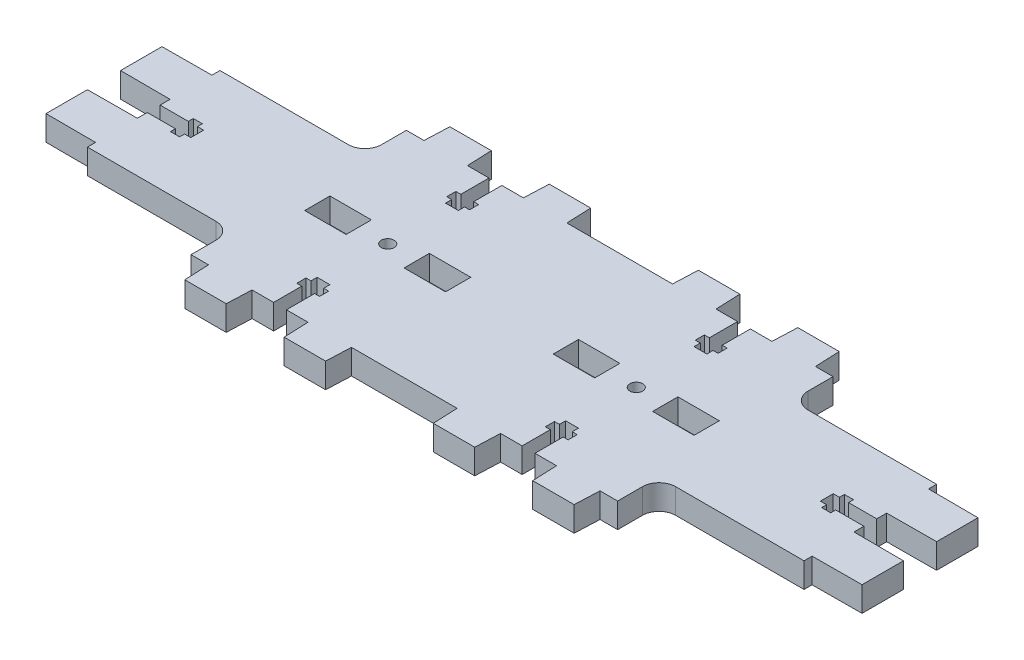
from build123d import *

# Parameters (mm, degrees)
SKETCH_1_R      = 1.55
SKETCH_1_W      = 10
SKETCH_1_H      = 6.1
EXTRUDE_1_DEPTH = 6


with BuildPart() as part:
    # Эскиз1 → Бобышка-Вытянуть1 (new body)
    with BuildSketch(Plane(origin=(0, 0, 0), x_dir=(1, 0, 0), z_dir=(0, 1, 0))):
        with BuildLine():
            Line((40.261608154, 29.273839185), (40.011608154, 23.273839185))
            Line((40.011608154, 23.273839185), (14.511608154, 23.273839185))
            Line((14.511608154, 23.273839185), (14.261608154, 29.273839185))
            Line((14.261608154, 29.273839185), (4.261608154, 29.273839185))
            Line((4.261608154, 29.273839185), (4.011608154, 23.273839185))
            Line((4.011608154, 23.273839185), (-1.188391846, 23.273839185))
            Line((-1.188391846, 23.273839185), (-1.188391846, 16.473839185))
            Line((-1.188391846, 16.473839185), (0.011608154, 16.473839185))
            Line((0.011608154, 16.473839185), (0.011608154, 14.273839185))
            Line((0.011608154, 14.273839185), (-1.188391846, 14.273839185))
            Line((-1.188391846, 14.273839185), (-1.188391846, 12.773839185))
            Line((-1.188391846, 12.773839185), (-4.288391846, 12.773839185))
            Line((-4.288391846, 12.773839185), (-4.288391846, 14.273839185))
            Line((-4.288391846, 14.273839185), (-5.488391846, 14.273839185))
            Line((-5.488391846, 14.273839185), (-5.488391846, 16.473839185))
            Line((-5.488391846, 16.473839185), (-4.288391846, 16.473839185))
            Line((-4.288391846, 16.473839185), (-4.288391846, 23.273839185))
            Line((-4.288391846, 23.273839185), (-9.488391846, 23.273839185))
            Line((-9.488391846, 23.273839185), (-9.738391846, 29.273839185))
            Line((-9.738391846, 29.273839185), (-19.738391846, 29.273839185))
            Line((-19.738391846, 29.273839185), (-19.988391846, 23.273839185))
            Line((-19.988391846, 23.273839185), (-24.238391846, 23.273839185))
            Line((-24.238391846, 23.273839185), (-24.238391846, 17.273839185))
            ThreePointArc((-24.238391846, 17.273839185), (-25.409964721, 14.44541206), (-28.238391846, 13.273839185))
            Line((-28.238391846, 13.273839185), (-59.238391846, 13.273839185))
            Line((-59.238391846, 13.273839185), (-59.238391846, 11.323839185))
            Line((-59.238391846, 11.323839185), (-71.238391846, 11.273839185))
            Line((-71.238391846, 11.273839185), (-71.238391846, 1.273839185))
            Line((-71.238391846, 1.273839185), (-59.238391846, 1.223839185))
            Line((-59.238391846, 1.223839185), (-59.238391846, -1.176160815))
            Line((-59.238391846, -1.176160815), (-52.438391846, -1.176160815))
            Line((-52.438391846, -1.176160815), (-52.438391846, 0.023839185))
            Line((-52.438391846, 0.023839185), (-50.238391846, 0.023839185))
            Line((-50.238391846, 0.023839185), (-50.238391846, -1.176160815))
            Line((-50.238391846, -1.176160815), (-48.738391846, -1.176160815))
            Line((-48.738391846, -1.176160815), (-48.738391846, -4.276160815))
            Line((-48.738391846, -4.276160815), (-50.238391846, -4.276160815))
            Line((-50.238391846, -4.276160815), (-50.238391846, -5.476160815))
            Line((-50.238391846, -5.476160815), (-52.438391846, -5.476160815))
            Line((-52.438391846, -5.476160815), (-52.438391846, -4.276160815))
            Line((-52.438391846, -4.276160815), (-59.238391846, -4.276160815))
            Line((-59.238391846, -4.276160815), (-59.238391846, -6.676160815))
            Line((-59.238391846, -6.676160815), (-71.238391846, -6.726160815))
            Line((-71.238391846, -6.726160815), (-71.238391846, -16.726160815))
            Line((-71.238391846, -16.726160815), (-59.238391846, -16.776160815))
            Line((-59.238391846, -16.776160815), (-59.238391846, -18.726160815))
            Line((-59.238391846, -18.726160815), (-28.238391846, -18.726160815))
            ThreePointArc((-28.238391846, -18.726160815), (-25.409964721, -19.897733691), (-24.238391846, -22.726160815))
            Line((-24.238391846, -22.726160815), (-24.238391846, -28.726160815))
            Line((-24.238391846, -28.726160815), (-19.988391846, -28.726160815))
            Line((-19.988391846, -28.726160815), (-19.738391846, -34.726160815))
            Line((-19.738391846, -34.726160815), (-9.738391846, -34.726160815))
            Line((-9.738391846, -34.726160815), (-9.488391846, -28.726160815))
            Line((-9.488391846, -28.726160815), (-4.288391846, -28.726160815))
            Line((-4.288391846, -28.726160815), (-4.288391846, -21.926160815))
            Line((-4.288391846, -21.926160815), (-5.488391846, -21.926160815))
            Line((-5.488391846, -21.926160815), (-5.488391846, -19.726160815))
            Line((-5.488391846, -19.726160815), (-4.288391846, -19.726160815))
            Line((-4.288391846, -19.726160815), (-4.288391846, -18.226160815))
            Line((-4.288391846, -18.226160815), (-1.188391846, -18.226160815))
            Line((-1.188391846, -18.226160815), (-1.188391846, -19.726160815))
            Line((-1.188391846, -19.726160815), (0.011608154, -19.726160815))
            Line((0.011608154, -19.726160815), (0.011608154, -21.926160815))
            Line((0.011608154, -21.926160815), (-1.188391846, -21.926160815))
            Line((-1.188391846, -21.926160815), (-1.188391846, -28.726160815))
            Line((-1.188391846, -28.726160815), (4.011608154, -28.726160815))
            Line((4.011608154, -28.726160815), (4.261608154, -34.726160815))
            Line((4.261608154, -34.726160815), (14.261608154, -34.726160815))
            Line((14.261608154, -34.726160815), (14.511608154, -28.726160815))
            Line((14.511608154, -28.726160815), (40.011608154, -28.726160815))
            Line((40.011608154, -28.726160815), (40.261608154, -34.726160815))
            Line((40.261608154, -34.726160815), (50.261608154, -34.726160815))
            Line((50.261608154, -34.726160815), (50.511608154, -28.726160815))
            Line((50.511608154, -28.726160815), (55.711608154, -28.726160815))
            Line((55.711608154, -28.726160815), (55.711608154, -21.926160815))
            Line((55.711608154, -21.926160815), (54.511608154, -21.926160815))
            Line((54.511608154, -21.926160815), (54.511608154, -19.726160815))
            Line((54.511608154, -19.726160815), (55.711608154, -19.726160815))
            Line((55.711608154, -19.726160815), (55.711608154, -18.226160815))
            Line((55.711608154, -18.226160815), (58.811608154, -18.226160815))
            Line((58.811608154, -18.226160815), (58.811608154, -19.726160815))
            Line((58.811608154, -19.726160815), (60.011608154, -19.726160815))
            Line((60.011608154, -19.726160815), (60.011608154, -21.926160815))
            Line((60.011608154, -21.926160815), (58.811608154, -21.926160815))
            Line((58.811608154, -21.926160815), (58.811608154, -28.726160815))
            Line((58.811608154, -28.726160815), (64.011608154, -28.726160815))
            Line((64.011608154, -28.726160815), (64.261608154, -34.726160815))
            Line((64.261608154, -34.726160815), (74.261608154, -34.726160815))
            Line((74.261608154, -34.726160815), (74.511608154, -28.726160815))
            Line((74.511608154, -28.726160815), (78.761608154, -28.726160815))
            Line((78.761608154, -28.726160815), (78.761608154, -22.726160815))
            ThreePointArc((78.761608154, -22.726160815), (79.933181029, -19.897733691), (82.761608154, -18.726160815))
            Line((82.761608154, -18.726160815), (113.761608154, -18.726160815))
            Line((113.761608154, -18.726160815), (113.761608154, -16.776160815))
            Line((113.761608154, -16.776160815), (125.761608154, -16.726160815))
            Line((125.761608154, -16.726160815), (125.761608154, -6.726160815))
            Line((125.761608154, -6.726160815), (113.761608154, -6.676160815))
            Line((113.761608154, -6.676160815), (113.761608154, -4.276160815))
            Line((113.761608154, -4.276160815), (106.961608154, -4.276160815))
            Line((106.961608154, -4.276160815), (106.961608154, -5.476160815))
            Line((106.961608154, -5.476160815), (104.761608154, -5.476160815))
            Line((104.761608154, -5.476160815), (104.761608154, -4.276160815))
            Line((104.761608154, -4.276160815), (103.261608154, -4.276160815))
            Line((103.261608154, -4.276160815), (103.261608154, -1.176160815))
            Line((103.261608154, -1.176160815), (104.761608154, -1.176160815))
            Line((104.761608154, -1.176160815), (104.761608154, 0.023839185))
            Line((104.761608154, 0.023839185), (106.961608154, 0.023839185))
            Line((106.961608154, 0.023839185), (106.961608154, -1.176160815))
            Line((106.961608154, -1.176160815), (113.761608154, -1.176160815))
            Line((113.761608154, -1.176160815), (113.761608154, 1.223839185))
            Line((113.761608154, 1.223839185), (125.761608154, 1.273839185))
            Line((125.761608154, 1.273839185), (125.761608154, 11.273839185))
            Line((125.761608154, 11.273839185), (113.761608154, 11.323839185))
            Line((113.761608154, 11.323839185), (113.761608154, 13.273839185))
            Line((113.761608154, 13.273839185), (82.761608154, 13.273839185))
            ThreePointArc((82.761608154, 13.273839185), (79.933181029, 14.44541206), (78.761608154, 17.273839185))
            Line((78.761608154, 17.273839185), (78.761608154, 23.273839185))
            Line((78.761608154, 23.273839185), (74.511608154, 23.273839185))
            Line((74.511608154, 23.273839185), (74.261608154, 29.273839185))
            Line((74.261608154, 29.273839185), (64.261608154, 29.273839185))
            Line((64.261608154, 29.273839185), (64.011608154, 23.273839185))
            Line((64.011608154, 23.273839185), (58.811608154, 23.273839185))
            Line((58.811608154, 23.273839185), (58.811608154, 16.473839185))
            Line((58.811608154, 16.473839185), (60.011608154, 16.473839185))
            Line((60.011608154, 16.473839185), (60.011608154, 14.273839185))
            Line((60.011608154, 14.273839185), (58.811608154, 14.273839185))
            Line((58.811608154, 14.273839185), (58.811608154, 12.773839185))
            Line((58.811608154, 12.773839185), (55.711608154, 12.773839185))
            Line((55.711608154, 12.773839185), (55.711608154, 14.273839185))
            Line((55.711608154, 14.273839185), (54.511608154, 14.273839185))
            Line((54.511608154, 14.273839185), (54.511608154, 16.473839185))
            Line((54.511608154, 16.473839185), (55.711608154, 16.473839185))
            Line((55.711608154, 16.473839185), (55.711608154, 23.273839185))
            Line((55.711608154, 23.273839185), (50.511608154, 23.273839185))
            Line((50.511608154, 23.273839185), (50.261608154, 29.273839185))
            Line((50.261608154, 29.273839185), (40.261608154, 29.273839185))
        make_face()
        with Locations((-2.738391846, -2.726160815)):
            Circle(SKETCH_1_R, mode=Mode.SUBTRACT)
        with Locations((57.261608154, -2.726160815)):
            Circle(SKETCH_1_R, mode=Mode.SUBTRACT)
        with Locations((9.261608154, -2.726160815)):
            Rectangle(SKETCH_1_W, SKETCH_1_H, mode=Mode.SUBTRACT)
        with Locations((-14.738391846, -2.726160815)):
            Rectangle(SKETCH_1_W, SKETCH_1_H, mode=Mode.SUBTRACT)
        with Locations((45.261608154, -2.726160815)):
            Rectangle(SKETCH_1_W, SKETCH_1_H, mode=Mode.SUBTRACT)
        with Locations((69.261608154, -2.726160815)):
            Rectangle(SKETCH_1_W, SKETCH_1_H, mode=Mode.SUBTRACT)
    extrude(amount=EXTRUDE_1_DEPTH)


solid = part.part
